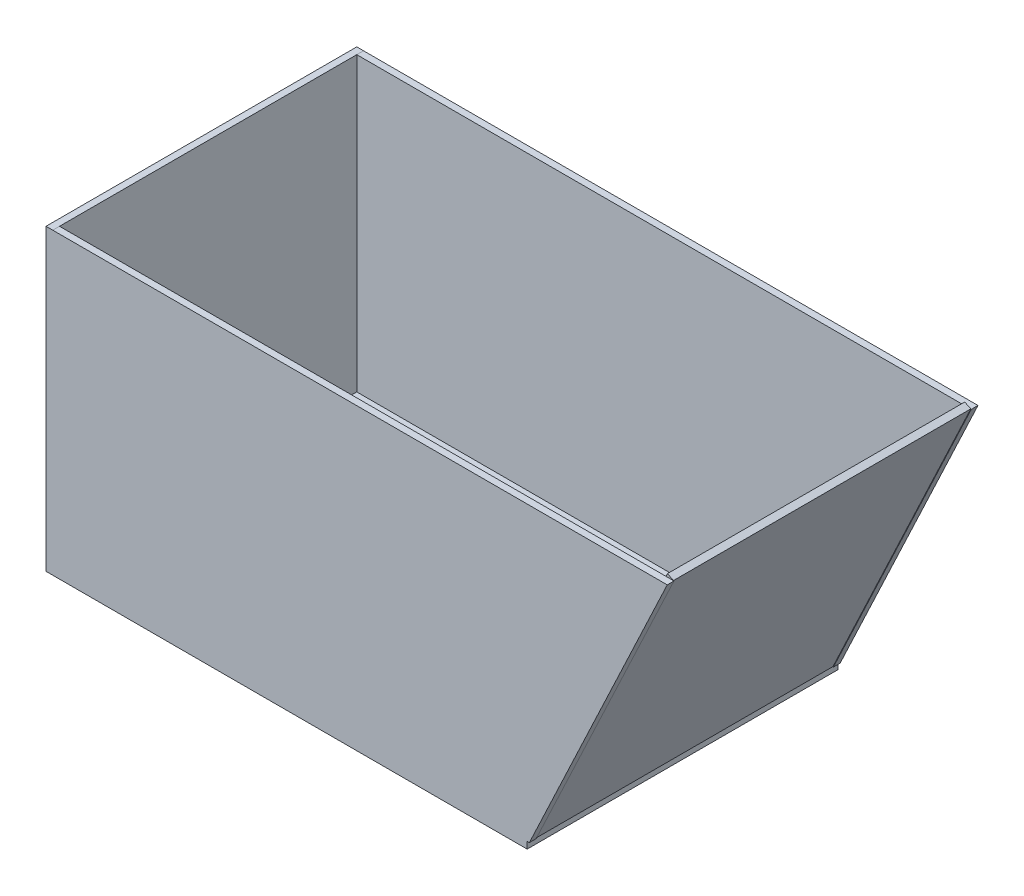
from build123d import *

# Parameters (mm, degrees)
SKETCH1_W           = 453
SKETCH1_H           = 292.569565374
BOSS_EXTRUDE1_DEPTH = 6.35
SKETCH2_W           = 6.35
SKETCH2_H           = 292.569565374
BOSS_EXTRUDE2_DEPTH = 275
BOSS_EXTRUDE3_DEPTH = 6.35
SKETCH5_W           = 279.869565374
SKETCH5_H           = 304.169578068
BOSS_EXTRUDE5_DEPTH = 6.35


with BuildPart() as part:
    # Sketch1 → Boss-Extrude1 (new body)
    with BuildSketch(Plane(origin=(0, 0, 0), x_dir=(1, 0, 0), z_dir=(0, 1, 0))):
        Rectangle(SKETCH1_W, SKETCH1_H)
    extrude(amount=BOSS_EXTRUDE1_DEPTH)

    # Sketch2 → Boss-Extrude2 (add)
    with BuildSketch(Plane(origin=(0, 6.35, 0), x_dir=(1, 0, 0), z_dir=(0, 1, 0))):
        with Locations((-223.325, 0)):
            Rectangle(SKETCH2_W, SKETCH2_H)
    extrude(amount=BOSS_EXTRUDE2_DEPTH)

    # Sketch4 → Boss-Extrude3 (add)
    with BuildSketch(Plane.XY.offset(146.284782687)):
        Polygon((358.392484654, 281.42327302), (228.570195765, 6.35), (-220.15, 6.35), (-220.15, 281.35), align=None)
    boss_extrude3 = extrude(amount=-BOSS_EXTRUDE3_DEPTH)

    # Mirror1: Boss-Extrude3 across plane
    add(boss_extrude3.mirror(Plane.XY))


with BuildPart() as body_2:
    # Sketch5 → Boss-Extrude5 (new body)
    with BuildSketch(Plane(origin=(184.065555905, -86.870714522, 0), x_dir=(0, 0, -1), z_dir=(0.904341831, -0.426808919, 0))):
        with Locations((0, 255.383157889)):
            Rectangle(SKETCH5_W, SKETCH5_H)
    extrude(amount=-BOSS_EXTRUDE5_DEPTH)


solid = Compound([part.part, body_2.part])
